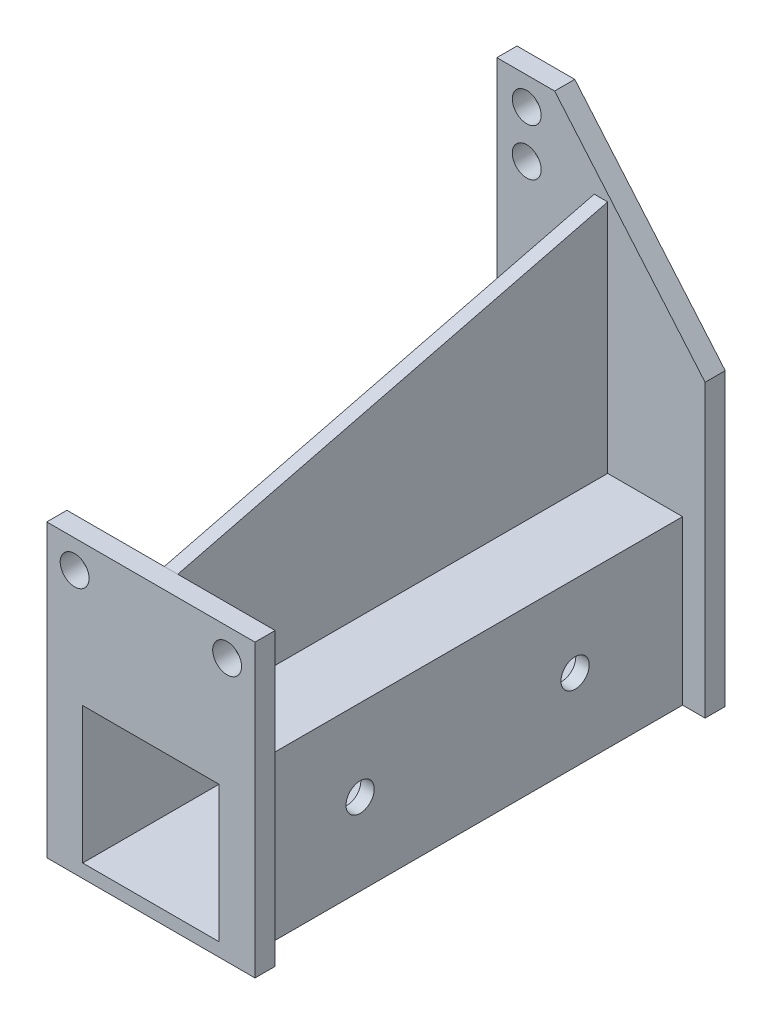
from build123d import *

# Parameters (mm, degrees)
CROQUIS1_W              = 24.3
CROQUIS1_H              = 24.3
CROQUIS1_W_2            = 20.3
CROQUIS1_H_2            = 20.3
SALIENTE_EXTRUIR1_DEPTH = 35
CROQUIS2_R              = 2.15
SALIENTE_EXTRUIR2_DEPTH = 3
CROQUIS3_R              = 2.15
SALIENTE_EXTRUIR3_DEPTH = 3
SALIENTE_EXTRUIR4_DEPTH = 1
CROQUIS5_R              = 2.1
CORTAR_EXTRUIR1_DEPTH   = 28.65


with BuildPart() as part:
    # Croquis1 → Saliente-Extruir1 (new body, symmetric)
    with BuildSketch(Plane.XY):
        Rectangle(CROQUIS1_W, CROQUIS1_H)
        Rectangle(CROQUIS1_W_2, CROQUIS1_H_2, mode=Mode.SUBTRACT)
    extrude(amount=SALIENTE_EXTRUIR1_DEPTH, both=True)

    # Croquis2 → Saliente-Extruir2 (add)
    with BuildSketch(Plane.XY.offset(35)):
        Polygon((15.5, -12.15), (15.5, 27), (15.5, 31.15), (-15.5, 31.15), (-15.5, -12.15), (-12.15, -12.15), (-12.15, 12.15), (12.15, 12.15), (12.15, -12.15), align=None)
        with Locations((-11.35, 27)):
            Circle(CROQUIS2_R, mode=Mode.SUBTRACT)
        with Locations((11.35, 27)):
            Circle(CROQUIS2_R, mode=Mode.SUBTRACT)
    extrude(amount=-SALIENTE_EXTRUIR2_DEPTH)

    # Croquis3 → Saliente-Extruir3 (add)
    with BuildSketch(Plane(origin=(0, 0, -35), x_dir=(-1, 0, 0), z_dir=(0, 0, -1))):
        Polygon((12.15, -12.15), (15.5, -12.15), (15.5, 57.5), (6.9, 57.5), (-15.5, 31.15), (-15.5, -12.15), (-12.15, -12.15), (-12.15, 12.15), (12.15, 12.15), align=None)
        with Locations((11.05, 53.35)):
            Circle(CROQUIS3_R, mode=Mode.SUBTRACT)
        with Locations((11.05, 46.35)):
            Circle(CROQUIS3_R, mode=Mode.SUBTRACT)
    extrude(amount=-SALIENTE_EXTRUIR3_DEPTH)

    # Croquis4 → Saliente-Extruir4 (add, symmetric)
    with BuildSketch(Plane(origin=(0, 0, 0), x_dir=(0, 0, -1), z_dir=(1, 0, 0))):
        Polygon((-32, 12.15), (32, 12.15), (32, 47.15), (-32, 31.15), align=None)
    extrude(amount=SALIENTE_EXTRUIR4_DEPTH, both=True)

    # Croquis5 → Cortar-Extruir1 (cut, through all)
    with BuildSketch(Plane(origin=(12.15, 0, 0), x_dir=(0, 0, -1), z_dir=(1, 0, 0))):
        with Locations((-16, 0)):
            Circle(CROQUIS5_R)
        with Locations((16, 0)):
            Circle(CROQUIS5_R)
    extrude(amount=-CORTAR_EXTRUIR1_DEPTH, mode=Mode.SUBTRACT)


solid = part.part
